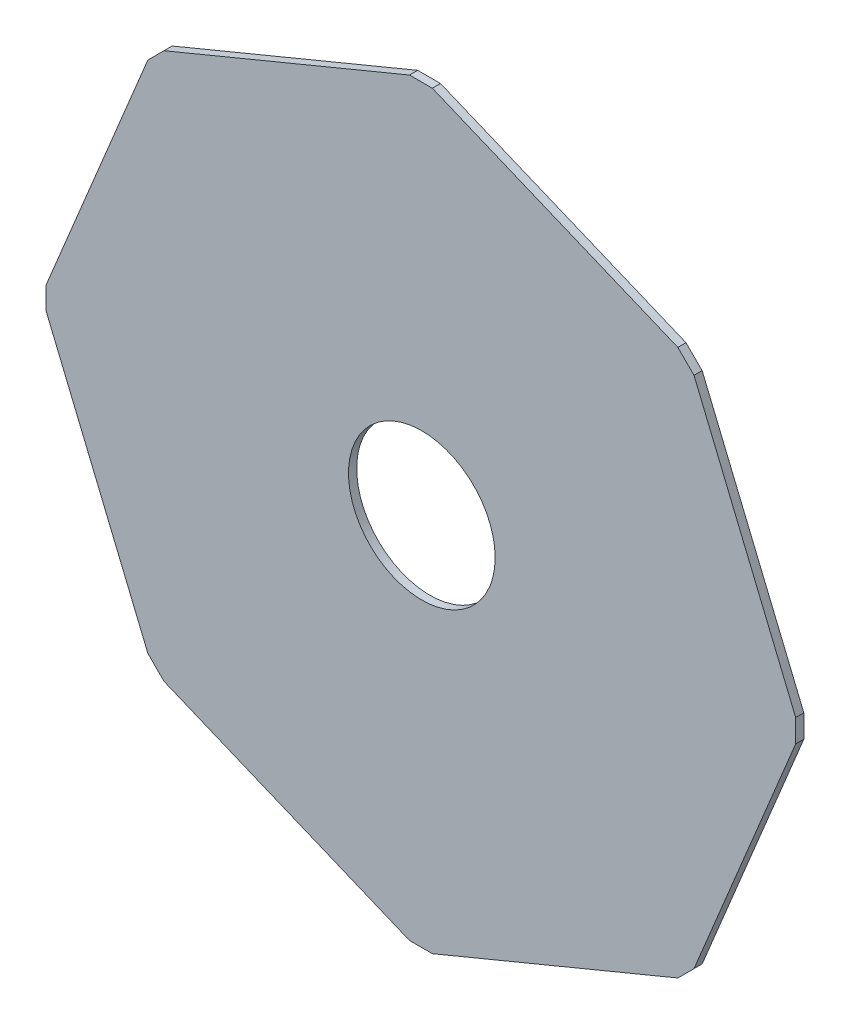
from build123d import *

# Parameters (mm, degrees)
SKETCH1_R           = 45
BOSS_EXTRUDE1_DEPTH = 5


with BuildPart() as part:
    # Sketch1 → Boss-Extrude1 (new body)
    with BuildSketch(Plane.XY):
        Polygon((-230.557942617, -6.721028691), (-168.142249758, -157.405840896), (-158.242754822, -167.305335833), (-7.557942617, -229.721028692), (6.442057383, -229.721028692), (157.126869588, -167.305335833), (167.026364524, -157.405840896), (229.442057383, -6.721028691), (229.442057383, 7.278971309), (167.026364524, 157.963783513), (157.126869588, 167.86327845), (6.442057383, 230.278971308), (-7.557942617, 230.278971308), (-158.242754822, 167.86327845), (-168.142249758, 157.963783513), (-230.557942617, 7.278971308), align=None)
        Circle(SKETCH1_R, mode=Mode.SUBTRACT)
    extrude(amount=BOSS_EXTRUDE1_DEPTH)


solid = part.part
